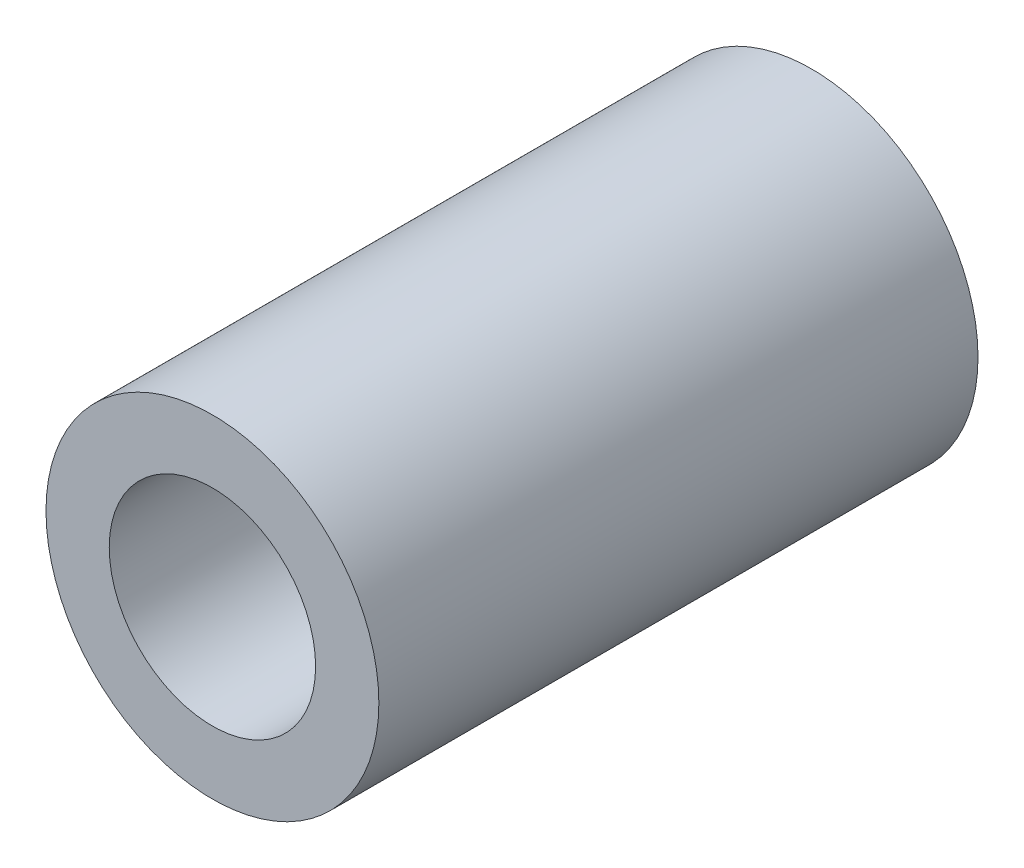
from build123d import *

# Parameters (mm, degrees)
SKETCH1_R           = 2.5
SKETCH1_R_2         = 1.55
BOSS_EXTRUDE1_DEPTH = 9


with BuildPart() as part:
    # Sketch1 → Boss-Extrude1 (new body)
    with BuildSketch(Plane.XY):
        Circle(SKETCH1_R)
        Circle(SKETCH1_R_2, mode=Mode.SUBTRACT)
    extrude(amount=BOSS_EXTRUDE1_DEPTH)


solid = part.part
